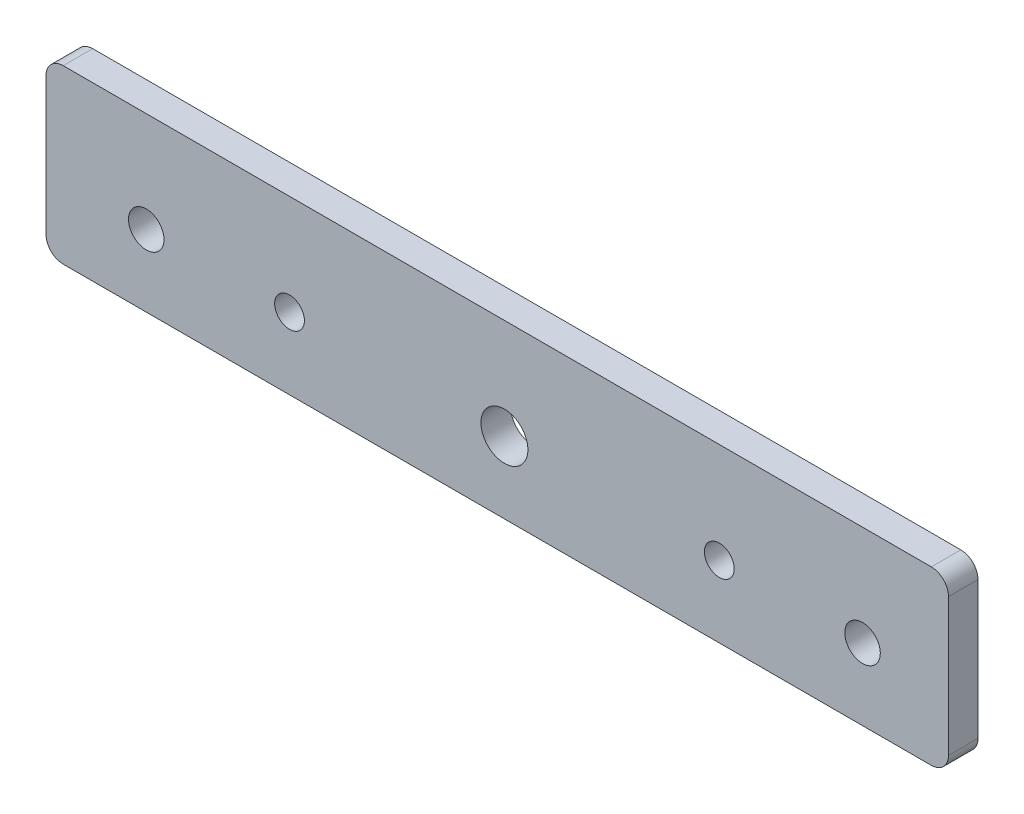
from build123d import *

# Parameters (mm, degrees)
SKETCH1_R           = 2.6
SKETCH1_R_2         = 3.1
SKETCH1_R_3         = 4.1
BOSS_EXTRUDE1_DEPTH = 5.15


with BuildPart() as part:
    # Sketch1 → Boss-Extrude1 (new body)
    with BuildSketch(Plane.XY):
        with BuildLine():
            Line((-77, 17.5), (74.5, 17.5))
            ThreePointArc((74.5, 17.5), (76.621320344, 16.621320344), (77.5, 14.5))
            Line((77.5, 14.5), (77.5, -9.5))
            ThreePointArc((77.5, -9.5), (76.621320344, -11.621320344), (74.5, -12.5))
            Line((74.5, -12.5), (-77, -12.5))
            ThreePointArc((-77, -12.5), (-79.121320344, -11.621320344), (-80, -9.5))
            Line((-80, -9.5), (-80, 14.5))
            ThreePointArc((-80, 14.5), (-79.121320344, 16.621320344), (-77, 17.5))
        make_face()
        with Locations((-37.5, 0)):
            Circle(SKETCH1_R, mode=Mode.SUBTRACT)
        with Locations((37.5, 0)):
            Circle(SKETCH1_R, mode=Mode.SUBTRACT)
        with Locations((-62.5, 0)):
            Circle(SKETCH1_R_2, mode=Mode.SUBTRACT)
        with Locations((62.5, 0)):
            Circle(SKETCH1_R_2, mode=Mode.SUBTRACT)
        Circle(SKETCH1_R_3, mode=Mode.SUBTRACT)
    extrude(amount=BOSS_EXTRUDE1_DEPTH)


solid = part.part
